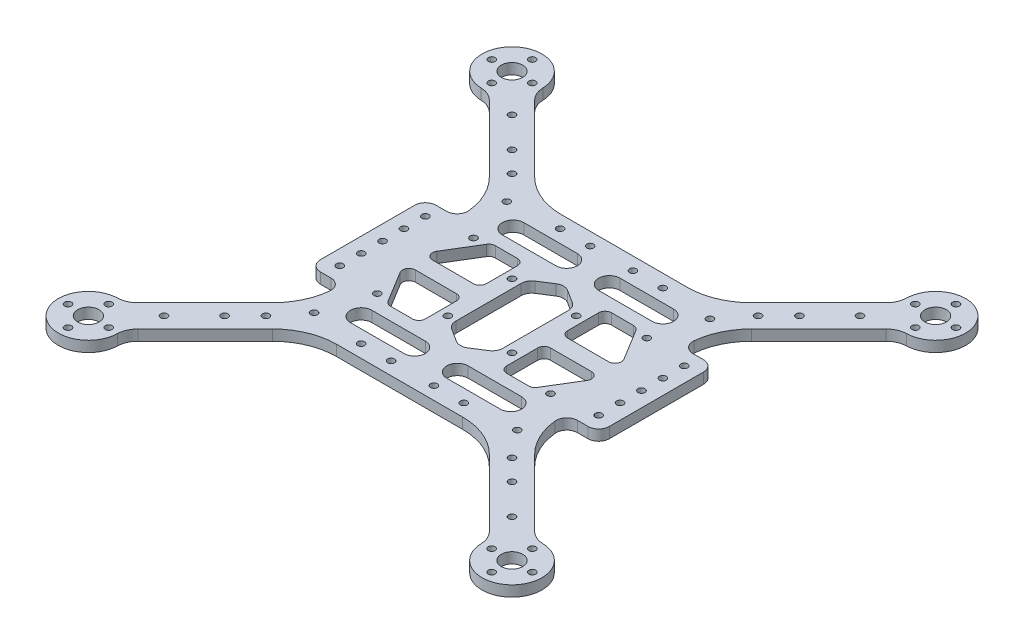
from build123d import *

# Parameters (mm, degrees)
SKETCH_1_R          = 1.6
SKETCH_1_R_2        = 5
EXTRUDE_1_DEPTH     = 5
SKETCH_2_R          = 1.6
CUT_EXTRUDE_1_DEPTH = 6
SKETCH_3_W          = 15
SKETCH_3_H          = 54
SKETCH_3_R          = 1.6
EXTRUDE_2_DEPTH     = 5
FILLET_1_R          = 30
FILLET_2_R          = 10
FILLET_3_R          = 5
FILLET_4_R          = 5
FILLET_5_R          = 5
FILLET_6_R          = 3
SKETCH_4_R          = 1.6
CUT_EXTRUDE_2_DEPTH = 6.0000001


with BuildPart() as part:
    # 草图1 → 凸台-拉伸1 (new body)
    with BuildSketch(Plane(origin=(0, 0, 0), x_dir=(1, 0, 0), z_dir=(0, 1, 0))):
        with BuildLine():
            Line((-41.893398282, -52.5), (41.893398282, -52.5))
            Line((41.893398282, -52.5), (85.332521759, -95.939123476))
            ThreePointArc((85.332521759, -95.939123476), (108.894444303, -108.894444303), (95.939123476, -85.332521759))
            Line((95.939123476, -85.332521759), (52.5, -41.893398282))
            Line((52.5, -41.893398282), (52.5, 41.893398282))
            Line((52.5, 41.893398282), (95.939123476, 85.332521759))
            ThreePointArc((95.939123476, 85.332521759), (108.894444303, 108.894444303), (85.332521759, 95.939123476))
            Line((85.332521759, 95.939123476), (41.893398282, 52.5))
            Line((41.893398282, 52.5), (-41.893398282, 52.5))
            Line((-41.893398282, 52.5), (-85.332521759, 95.939123476))
            ThreePointArc((-85.332521759, 95.939123476), (-108.894444303, 108.894444303), (-95.939123476, 85.332521759))
            Line((-95.939123476, 85.332521759), (-52.5, 41.893398282))
            Line((-52.5, 41.893398282), (-52.5, -41.893398282))
            Line((-52.5, -41.893398282), (-95.939123476, -85.332521759))
            ThreePointArc((-95.939123476, -85.332521759), (-108.894444303, -108.894444303), (-85.332521759, -95.939123476))
            Line((-85.332521759, -95.939123476), (-41.893398282, -52.5))
        make_face()
        with Locations((-47.5, 45)):
            Circle(SKETCH_1_R, mode=Mode.SUBTRACT)
        with Locations((47.5, 45)):
            Circle(SKETCH_1_R, mode=Mode.SUBTRACT)
        with Locations((-47.5, -45)):
            Circle(SKETCH_1_R, mode=Mode.SUBTRACT)
        with Locations((47.5, -45)):
            Circle(SKETCH_1_R, mode=Mode.SUBTRACT)
        with Locations((-98.994949366, 108.494949366)):
            Circle(SKETCH_1_R, mode=Mode.SUBTRACT)
        with Locations((-89.494949366, 98.994949366)):
            Circle(SKETCH_1_R, mode=Mode.SUBTRACT)
        with Locations((-98.994949366, 89.494949366)):
            Circle(SKETCH_1_R, mode=Mode.SUBTRACT)
        with Locations((-108.494949366, 98.994949366)):
            Circle(SKETCH_1_R, mode=Mode.SUBTRACT)
        with Locations((-98.994949366, 98.994949366)):
            Circle(SKETCH_1_R_2, mode=Mode.SUBTRACT)
        with Locations((108.494949366, 98.994949366)):
            Circle(SKETCH_1_R, mode=Mode.SUBTRACT)
        with Locations((98.994949366, 89.494949366)):
            Circle(SKETCH_1_R, mode=Mode.SUBTRACT)
        with Locations((89.494949366, 98.994949366)):
            Circle(SKETCH_1_R, mode=Mode.SUBTRACT)
        with Locations((98.994949366, 108.494949366)):
            Circle(SKETCH_1_R, mode=Mode.SUBTRACT)
        with Locations((98.994949366, 98.994949366)):
            Circle(SKETCH_1_R_2, mode=Mode.SUBTRACT)
        with Locations((-89.494949366, -98.994949366)):
            Circle(SKETCH_1_R, mode=Mode.SUBTRACT)
        with Locations((-98.994949366, -108.494949366)):
            Circle(SKETCH_1_R, mode=Mode.SUBTRACT)
        with Locations((-98.994949366, -98.994949366)):
            Circle(SKETCH_1_R_2, mode=Mode.SUBTRACT)
        with Locations((-98.994949366, -89.494949366)):
            Circle(SKETCH_1_R, mode=Mode.SUBTRACT)
        with Locations((-108.494949366, -98.994949366)):
            Circle(SKETCH_1_R, mode=Mode.SUBTRACT)
        with Locations((98.994949366, -89.494949366)):
            Circle(SKETCH_1_R, mode=Mode.SUBTRACT)
        with Locations((108.494949366, -98.994949366)):
            Circle(SKETCH_1_R, mode=Mode.SUBTRACT)
        with Locations((98.994949366, -108.494949366)):
            Circle(SKETCH_1_R, mode=Mode.SUBTRACT)
        with Locations((98.994949366, -98.994949366)):
            Circle(SKETCH_1_R_2, mode=Mode.SUBTRACT)
        with Locations((89.494949366, -98.994949366)):
            Circle(SKETCH_1_R, mode=Mode.SUBTRACT)
        with Locations((-67.175144213, 67.175144213)):
            Circle(SKETCH_1_R, mode=Mode.SUBTRACT)
        with Locations((-81.317279836, 81.317279836)):
            Circle(SKETCH_1_R, mode=Mode.SUBTRACT)
        with Locations((-67.175144213, -67.175144213)):
            Circle(SKETCH_1_R, mode=Mode.SUBTRACT)
        with Locations((-81.317279836, -81.317279836)):
            Circle(SKETCH_1_R, mode=Mode.SUBTRACT)
        with Locations((67.175144213, -67.175144213)):
            Circle(SKETCH_1_R, mode=Mode.SUBTRACT)
        with Locations((81.317279836, -81.317279836)):
            Circle(SKETCH_1_R, mode=Mode.SUBTRACT)
        with Locations((67.175144213, 67.175144213)):
            Circle(SKETCH_1_R, mode=Mode.SUBTRACT)
        with Locations((81.317279836, 81.317279836)):
            Circle(SKETCH_1_R, mode=Mode.SUBTRACT)
    extrude(amount=EXTRUDE_1_DEPTH)

    # 草图2 → 切除-拉伸1 (cut, through all)
    with BuildSketch(Plane(origin=(0, 5, 0), x_dir=(1, 0, 0), z_dir=(0, 1, 0))):
        with Locations((-40.5, 22.5)):
            Circle(SKETCH_2_R)
        with Locations((-40.5, -22.5)):
            Circle(SKETCH_2_R)
        with Locations((40.5, -22.5)):
            Circle(SKETCH_2_R)
        with Locations((40.5, 22.5)):
            Circle(SKETCH_2_R)
        with Locations((-24, 46.5)):
            Circle(SKETCH_2_R)
        with Locations((24, 46.5)):
            Circle(SKETCH_2_R)
        with Locations((24, -46.5)):
            Circle(SKETCH_2_R)
        with Locations((-24, -46.5)):
            Circle(SKETCH_2_R)
        with Locations((-15, 15)):
            Circle(SKETCH_2_R)
        with Locations((15, 15)):
            Circle(SKETCH_2_R)
        with Locations((15, -15)):
            Circle(SKETCH_2_R)
        with Locations((-15, -15)):
            Circle(SKETCH_2_R)
        with Locations((-10, 46.5)):
            Circle(SKETCH_2_R)
        with Locations((10, 46.5)):
            Circle(SKETCH_2_R)
        with Locations((10, -46.5)):
            Circle(SKETCH_2_R)
        with Locations((-10, -46.5)):
            Circle(SKETCH_2_R)
        Polygon((-11, 18), (-11, -18), (0, -25), (11, -18), (11, 18), (0, 25), align=None)
        with BuildLine():
            Line((-10, 30.5), (-35, 30.5))
            ThreePointArc((-35, 30.5), (-40, 35.5), (-35, 40.5))
            Line((-35, 40.5), (-10, 40.5))
            ThreePointArc((-10, 40.5), (-5, 35.5), (-10, 30.5))
        make_face()
        with BuildLine():
            Line((10, 30.5), (35, 30.5))
            ThreePointArc((35, 30.5), (40, 35.5), (35, 40.5))
            Line((35, 40.5), (10, 40.5))
            ThreePointArc((10, 40.5), (5, 35.5), (10, 30.5))
        make_face()
        with BuildLine():
            Line((-10, -30.5), (-35, -30.5))
            ThreePointArc((-35, -30.5), (-40, -35.5), (-35, -40.5))
            Line((-35, -40.5), (-10, -40.5))
            ThreePointArc((-10, -40.5), (-5, -35.5), (-10, -30.5))
        make_face()
        with BuildLine():
            Line((10, -30.5), (35, -30.5))
            ThreePointArc((35, -30.5), (40, -35.5), (35, -40.5))
            Line((35, -40.5), (10, -40.5))
            ThreePointArc((10, -40.5), (5, -35.5), (10, -30.5))
        make_face()
        Polygon((-46.5, 4), (-19, 4), (-19, 24.5), (-34, 24.5), align=None)
        Polygon((-19, -24.5), (-34, -24.5), (-46.5, -4), (-19, -4), align=None)
        Polygon((19, -4), (19, -24.5), (34, -24.5), (46.5, -4), align=None)
        Polygon((19, 24.5), (34, 24.5), (46.5, 4), (19, 4), align=None)
    extrude(amount=-CUT_EXTRUDE_1_DEPTH, mode=Mode.SUBTRACT)

    # 草图3 → 凸台-拉伸2 (add)
    with BuildSketch(Plane(origin=(0, 5, 0), x_dir=(1, 0, 0), z_dir=(0, 1, 0))):
        with Locations((-60, 0)):
            Rectangle(SKETCH_3_W, SKETCH_3_H)
        with Locations((-60.5, 20)):
            Circle(SKETCH_3_R, mode=Mode.SUBTRACT)
        with Locations((-60.5, -20)):
            Circle(SKETCH_3_R, mode=Mode.SUBTRACT)
        with Locations((-60.5, 10)):
            Circle(SKETCH_3_R, mode=Mode.SUBTRACT)
        with Locations((-60.5, -10)):
            Circle(SKETCH_3_R, mode=Mode.SUBTRACT)
        with Locations((-60.5, 0)):
            Circle(SKETCH_3_R, mode=Mode.SUBTRACT)
        with Locations((60, 0)):
            Rectangle(SKETCH_3_W, SKETCH_3_H)
        with Locations((60.5, -20)):
            Circle(SKETCH_3_R, mode=Mode.SUBTRACT)
        with Locations((60.5, 20)):
            Circle(SKETCH_3_R, mode=Mode.SUBTRACT)
        with Locations((60.5, -10)):
            Circle(SKETCH_3_R, mode=Mode.SUBTRACT)
        with Locations((60.5, 10)):
            Circle(SKETCH_3_R, mode=Mode.SUBTRACT)
        with Locations((60.5, 0)):
            Circle(SKETCH_3_R, mode=Mode.SUBTRACT)
    extrude(amount=-EXTRUDE_2_DEPTH)

    # 圆角1
    fillet_1_edges = [part.edges().sort_by_distance(p)[0] for p in [
        (-41.893398282, 2.5, -52.5),
        (41.893398282, 2.5, -52.5),
        (52.5, 2.5, -41.893398282),
        (52.5, 2.5, 41.893398282),
        (41.893398282, 2.5, 52.5),
        (-41.893398282, 2.5, 52.5),
        (-52.5, 2.5, 41.893398282),
        (-52.5, 2.5, -41.893398282),
    ]]
    fillet(fillet_1_edges, radius=FILLET_1_R)

    # 圆角2
    fillet_2_edges = [part.edges().sort_by_distance(p)[0] for p in [
        (-95.939123476, 2.5, -85.332521759),
        (-85.332521759, 2.5, -95.939123476),
        (85.332521759, 2.5, -95.939123476),
        (95.939123476, 2.5, -85.332521759),
        (95.939123476, 2.5, 85.332521759),
        (85.332521759, 2.5, 95.939123476),
        (-85.332521759, 2.5, 95.939123476),
        (-95.939123476, 2.5, 85.332521759),
    ]]
    fillet(fillet_2_edges, radius=FILLET_2_R)

    # 圆角3
    fillet_3_edges = [part.edges().sort_by_distance(p)[0] for p in [
        (-67.5, 2.5, -27),
        (-67.5, 2.5, 27),
        (67.5, 2.5, 27),
        (67.5, 2.5, -27),
    ]]
    fillet(fillet_3_edges, radius=FILLET_3_R)

    # 圆角4
    fillet_4_edges = [part.edges().sort_by_distance(p)[0] for p in [
        (-52.5, 2.5, 27),
        (-52.5, 2.5, -27),
        (52.5, 2.5, -27),
        (52.5, 2.5, 27),
    ]]
    fillet(fillet_4_edges, radius=FILLET_4_R)

    # 圆角5
    fillet_5_edges = [part.edges().sort_by_distance(p)[0] for p in [
        (-11, 2.5, -18),
        (0, 2.5, -25),
        (11, 2.5, -18),
        (11, 2.5, 18),
        (0, 2.5, 25),
        (-11, 2.5, 18),
    ]]
    fillet(fillet_5_edges, radius=FILLET_5_R)

    # 圆角6
    fillet_6_edges = [part.edges().sort_by_distance(p)[0] for p in [
        (19, 2.5, -4),
        (19, 2.5, -24.5),
        (34, 2.5, -24.5),
        (46.5, 2.5, -4),
        (19, 2.5, 4),
        (46.5, 2.5, 4),
        (34, 2.5, 24.5),
        (19, 2.5, 24.5),
        (-19, 2.5, 4),
        (-19, 2.5, 24.5),
        (-34, 2.5, 24.5),
        (-46.5, 2.5, 4),
        (-46.5, 2.5, -4),
        (-34, 2.5, -24.5),
        (-19, 2.5, -24.5),
        (-19, 2.5, -4),
    ]]
    fillet(fillet_6_edges, radius=FILLET_6_R)

    # 草图4 → 切除-拉伸2 (cut, through all)
    with BuildSketch(Plane(origin=(0, 5, 0), x_dir=(1, 0, 0), z_dir=(0, 1, 0))):
        with Locations((-57.5, 57.5)):
            Circle(SKETCH_4_R)
        with Locations((57.5, 57.5)):
            Circle(SKETCH_4_R)
        with Locations((-57.5, -57.5)):
            Circle(SKETCH_4_R)
        with Locations((57.5, -57.5)):
            Circle(SKETCH_4_R)
    extrude(amount=-CUT_EXTRUDE_2_DEPTH, mode=Mode.SUBTRACT)


solid = part.part
